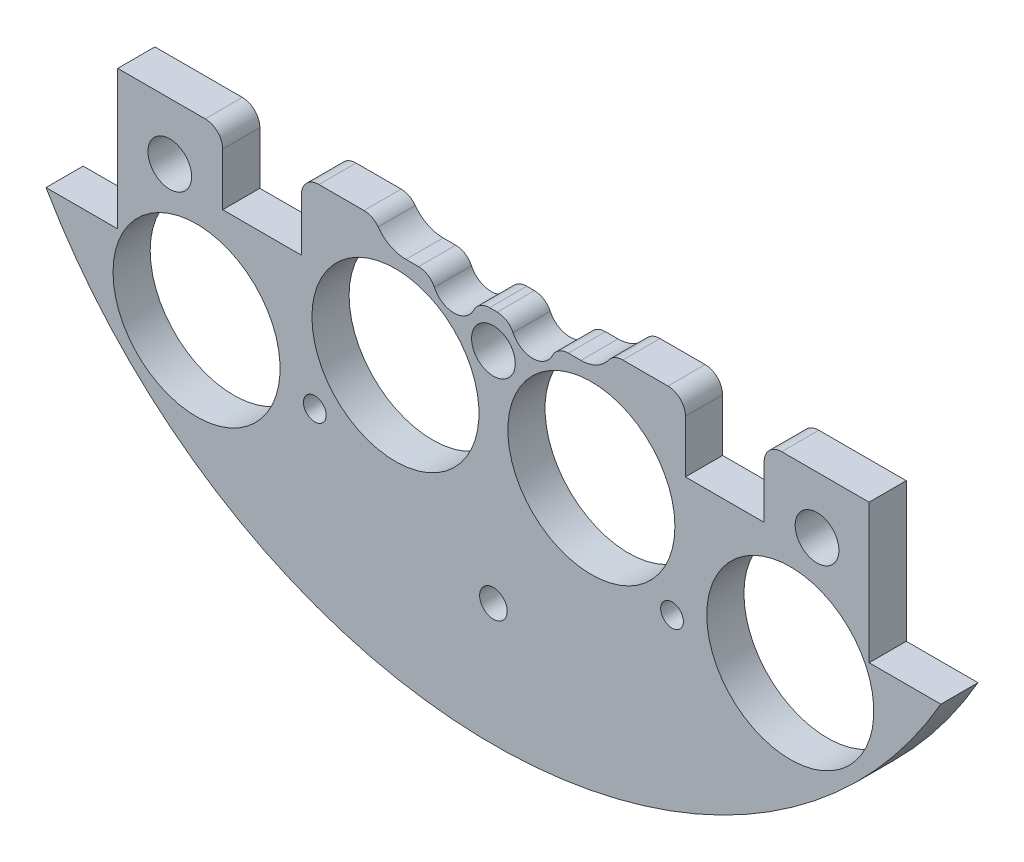
from build123d import *

# Parameters (mm, degrees)
SKETCH1_R                 = 1.651
BOSS_EXTRUDE2_DEPTH       = 5.3975
SKETCH2_R                 = 1.143
CUT_EXTRUDE1_DEPTH        = 6.3975
SKETCH3_R                 = 12.1285
CUT_EXTRUDE2_DEPTH        = 6.3975
SKETCH4_W                 = 28.562713242
SKETCH4_H                 = 11.677503754
BOSS_EXTRUDE3_DEPTH       = 5.3975
SKETCH5_W                 = 216.7214489
SKETCH5_H                 = 130.569220634
CUT_EXTRUDE4_DEPTH        = 6.3975
SKETCH7_R                 = 2
CUT_EXTRUDE5_DEPTH        = 23.368
SKETCH11_W                = 11.43
SKETCH11_H                = 10.16
CUT_EXTRUDE9_DEPTH        = 6.3975
SKETCH67_R                = 1.651
CUT_EXTRUDE65_DEPTH       = 97.79
SKETCH121_R               = 3.175
CUT_EXTRUDE119_DEPTH      = 103.378
CUT_EXTRUDE119_DEPTH_BACK = 48.768
CUT_EXTRUDE12_DEPTH       = 10
FILLET1_R                 = 2.54


with BuildPart() as part:
    # Sketch1 → Boss-Extrude2 (new body)
    with BuildSketch(Plane.XY):
        with BuildLine():
            Line((-64.964441474, 37.338), (-54.550441474, 37.338))
            Line((-54.550441474, 37.338), (-54.550441474, -37.338))
            Line((-54.550441474, -37.338), (-64.964441474, -37.338))
            ThreePointArc((-64.964441474, -37.338), (0, -74.93), (64.964441474, -37.338))
            Line((64.964441474, -37.338), (54.550441474, -37.338))
            Line((54.550441474, -37.338), (54.550441474, 37.338))
            Line((54.550441474, 37.338), (64.964441474, 37.338))
            ThreePointArc((64.964441474, 37.338), (0, 74.93), (-64.964441474, 37.338))
        make_face()
        with Locations((-46.482, 11.049)):
            Circle(SKETCH1_R, mode=Mode.SUBTRACT)
        with Locations((-21.083270032, 10.795)):
            Circle(SKETCH1_R, mode=Mode.SUBTRACT)
        with Locations((-21.083270032, -10.795)):
            Circle(SKETCH1_R, mode=Mode.SUBTRACT)
        with Locations((-46.482, -11.049)):
            Circle(SKETCH1_R, mode=Mode.SUBTRACT)
        with Locations((46.482, -11.049)):
            Circle(SKETCH1_R, mode=Mode.SUBTRACT)
        with Locations((21.083270032, -10.795)):
            Circle(SKETCH1_R, mode=Mode.SUBTRACT)
        with Locations((21.083270032, 10.795)):
            Circle(SKETCH1_R, mode=Mode.SUBTRACT)
        with Locations((46.482, 11.049)):
            Circle(SKETCH1_R, mode=Mode.SUBTRACT)
    extrude(amount=BOSS_EXTRUDE2_DEPTH)

    # Sketch2 → Cut-Extrude1 (cut, through all)
    with BuildSketch(Plane.XY.offset(5.3975)):
        with Locations((-6.731, 62.23)):
            Circle(SKETCH2_R)
        with Locations((6.731, 62.23)):
            Circle(SKETCH2_R)
    extrude(amount=-CUT_EXTRUDE1_DEPTH, mode=Mode.SUBTRACT)

    # Sketch3 → Cut-Extrude2 (cut, through all)
    with BuildSketch(Plane(origin=(0, 0, 0), x_dir=(-1, 0, 0), z_dir=(0, 0, -1))):
        with Locations((-43.105229381, -43.105229381)):
            Circle(SKETCH3_R)
        with Locations((14.224, -34.29)):
            Circle(SKETCH3_R)
        with Locations((14.224, 34.29)):
            Circle(SKETCH3_R)
        with Locations((-43.105229381, 43.105229381)):
            Circle(SKETCH3_R)
        with Locations((43.105229381, 43.105229381)):
            Circle(SKETCH3_R)
        with Locations((-14.224, 34.29)):
            Circle(SKETCH3_R)
        with Locations((-14.224, -34.29)):
            Circle(SKETCH3_R)
        with Locations((43.105229381, -43.105229381)):
            Circle(SKETCH3_R)
    extrude(amount=-CUT_EXTRUDE2_DEPTH, mode=Mode.SUBTRACT)

    # Sketch4 → Boss-Extrude3 (add)
    with BuildSketch(Plane(origin=(0, 0, 0), x_dir=(-1, 0, 0), z_dir=(0, 0, -1))):
        with Locations((-1.488809975, 62.152540216)):
            Rectangle(SKETCH4_W, SKETCH4_H)
    extrude(amount=-BOSS_EXTRUDE3_DEPTH)

    # Sketch5 → Cut-Extrude4 (cut, through all)
    with BuildSketch(Plane(origin=(0, 0, 0), x_dir=(-1, 0, 0), z_dir=(0, 0, -1))):
        with Locations((23.316688373, 48.139610317)):
            Rectangle(SKETCH5_W, SKETCH5_H)
    extrude(amount=-CUT_EXTRUDE4_DEPTH, mode=Mode.SUBTRACT)

    # Sketch7 → Cut-Extrude5 (cut)
    with BuildSketch(Plane(origin=(0, 0, 0), x_dir=(-1, 0, 0), z_dir=(0, 0, -1))):
        with Locations((0, -57.145)):
            Circle(SKETCH7_R)
    extrude(amount=-CUT_EXTRUDE5_DEPTH, mode=Mode.SUBTRACT)

    # Sketch11 → Cut-Extrude9 (cut, through all)
    with BuildSketch(Plane(origin=(0, 0, 0), x_dir=(-1, 0, 0), z_dir=(0, 0, -1))):
        with Locations((-33.595441474, -22.225)):
            Rectangle(SKETCH11_W, SKETCH11_H)
        with Locations((33.595441474, -22.225)):
            Rectangle(SKETCH11_W, SKETCH11_H)
    extrude(amount=-CUT_EXTRUDE9_DEPTH, mode=Mode.SUBTRACT)

    # Sketch67 → Cut-Extrude65 (cut)
    with BuildSketch(Plane(origin=(30.092005081, 4.08352975, -19.2405), x_dir=(-1, 0, 0), z_dir=(0, 0, -1))):
        with Locations((4.154396091, -49.728759131)):
            Circle(SKETCH67_R)
        with Locations((56.02961407, -49.728759131)):
            Circle(SKETCH67_R)
    extrude(amount=-CUT_EXTRUDE65_DEPTH, mode=Mode.SUBTRACT)

    # Sketch121 → Cut-Extrude119 (cut, two sides)
    with BuildSketch(Plane(origin=(30.092005081, 4.08352975, 16.891), x_dir=(-1, 0, 0), z_dir=(0, 0, -1))) as cut_extrude119_sk:
        with Locations((77.082005081, -29.48352975)):
            Circle(SKETCH121_R)
        with Locations((30.092005081, -29.48352975)):
            Circle(SKETCH121_R)
        with Locations((-16.897994919, -29.48352975)):
            Circle(SKETCH121_R)
    extrude(amount=CUT_EXTRUDE119_DEPTH, mode=Mode.SUBTRACT)
    extrude(cut_extrude119_sk.sketch, amount=-CUT_EXTRUDE119_DEPTH_BACK, mode=Mode.SUBTRACT)

    # Sketch14 → Cut-Extrude12 (cut)
    with BuildSketch(Plane.XY.offset(5.3975)):
        with BuildLine():
            Line((12.7, -20.24), (8.888991966, -20.24))
            ThreePointArc((8.888991966, -20.24), (5.715, -23.495), (2.541008034, -20.24))
            Line((2.541008034, -20.24), (-2.541008034, -20.24))
            ThreePointArc((-2.541008034, -20.24), (-5.715, -23.495), (-8.888991966, -20.24))
            Line((-8.888991966, -20.24), (-12.7, -20.24))
            ThreePointArc((-12.7, -20.24), (-16.235533906, -11.704466094), (-7.7, -15.24))
            Line((-7.7, -15.24), (7.7, -15.24))
            ThreePointArc((7.7, -15.24), (16.235533906, -11.704466094), (12.7, -20.24))
        make_face()
    extrude(amount=-CUT_EXTRUDE12_DEPTH, mode=Mode.SUBTRACT)

    # Fillet1
    fillet1_edges = [part.edges().sort_by_distance(p)[0] for p in [
        (39.310441474, -17.145, 2.69875),
        (27.880441474, -17.145, 2.69875),
        (-27.880441474, -17.145, 2.69875),
        (-39.310441474, -17.145, 2.69875),
        (-2.541008034, -20.24, 2.69875),
        (-8.888991966, -20.24, 2.69875),
        (-17.322875188, -17.145, 2.69875),
        (17.322875188, -17.145, 2.69875),
        (8.888991966, -20.24, 2.69875),
        (2.541008034, -20.24, 2.69875),
    ]]
    fillet(fillet1_edges, radius=FILLET1_R)


solid = part.part
